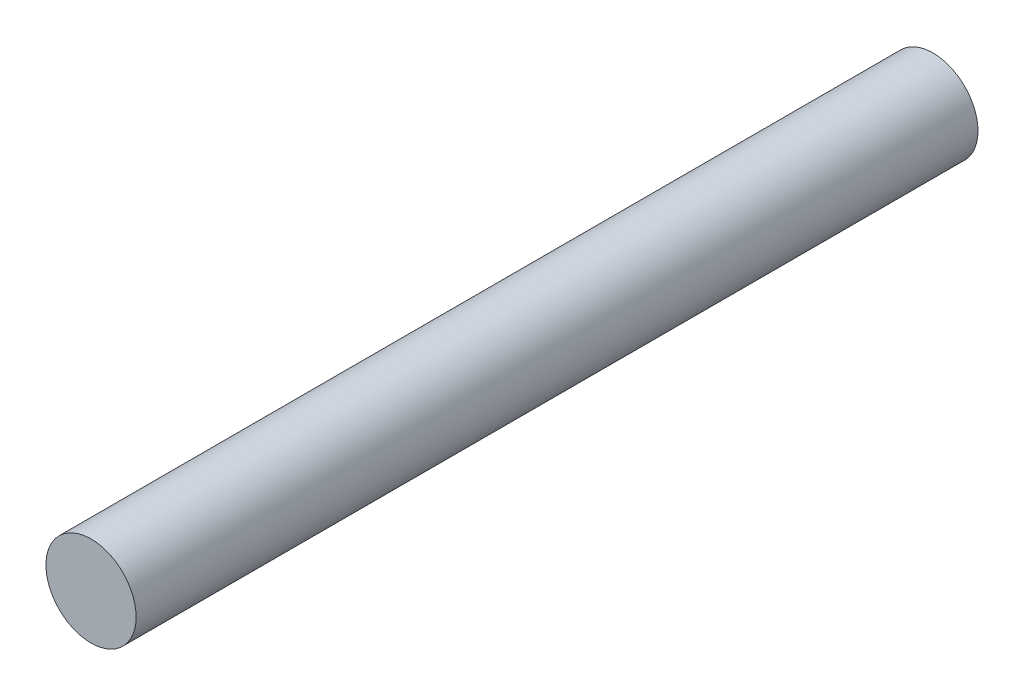
from build123d import *

# Parameters (mm, degrees)
SKETCH1_R           = 0.75
BOSS_EXTRUDE1_DEPTH = 7


with BuildPart() as part:
    # Sketch1 → Boss-Extrude1 (new body, symmetric)
    with BuildSketch(Plane.XY):
        Circle(SKETCH1_R)
    extrude(amount=BOSS_EXTRUDE1_DEPTH, both=True)


solid = part.part
